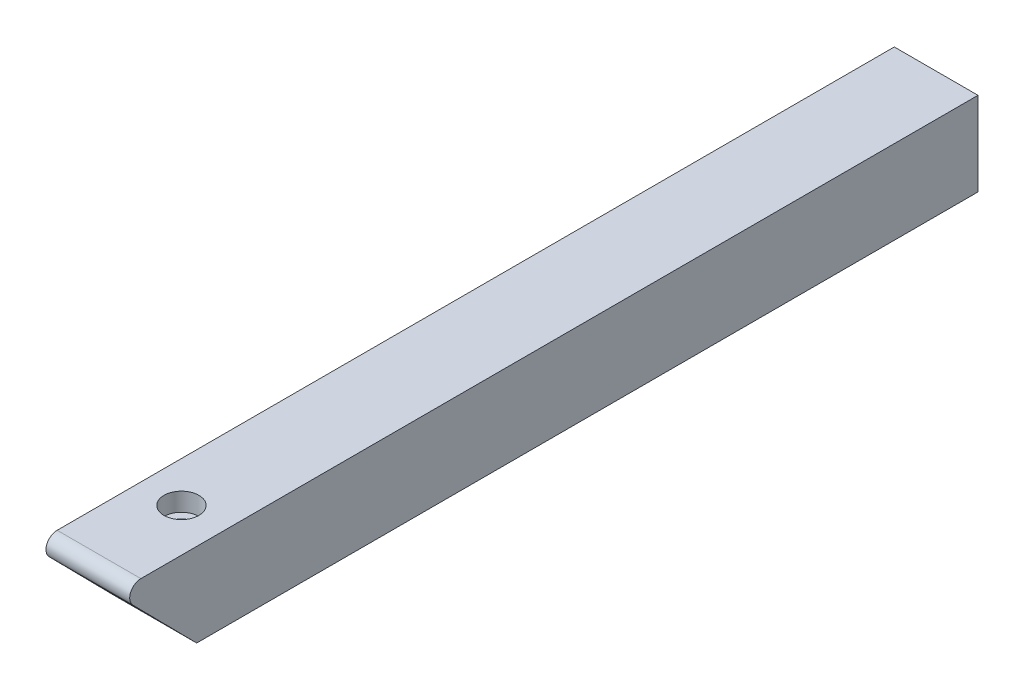
from build123d import *

# Parameters (mm, degrees)
SKETCH1_W                                      = 19.05
SKETCH1_H                                      = 19.05
BOSS_EXTRUDE1_DEPTH                            = 177.8
BOSS_EXTRUDE2_DEPTH                            = 19.05
CBORE_FOR_8_SOCKET_HEAD_CAP_SCREW1_D           = 4.3053
CBORE_FOR_8_SOCKET_HEAD_CAP_SCREW1_DEPTH       = 19.05
CBORE_FOR_8_SOCKET_HEAD_CAP_SCREW1_CBORE_D     = 7.9375
CBORE_FOR_8_SOCKET_HEAD_CAP_SCREW1_CBORE_DEPTH = 4.1656


with BuildPart() as part:
    # Sketch1 → Boss-Extrude1 (new body)
    with BuildSketch(Plane.XY):
        with Locations((9.525, 9.525)):
            Rectangle(SKETCH1_W, SKETCH1_H)
    extrude(amount=BOSS_EXTRUDE1_DEPTH)

    # Sketch2 → Boss-Extrude2 (add)
    with BuildSketch(Plane(origin=(19.05, 0, 0), x_dir=(0, 0, -1), z_dir=(1, 0, 0))):
        with BuildLine():
            Line((-177.8, 19.05), (-190.5, 19.05))
            ThreePointArc((-190.5, 19.05), (-192.843013973, 17.490757626), (-192.309392774, 14.727390174))
            Line((-192.309392774, 14.727390174), (-177.8, 0))
            Line((-177.8, 0), (-177.8, 19.05))
        make_face()
    extrude(amount=-BOSS_EXTRUDE2_DEPTH)

    # CBORE for #8 Socket Head Cap Screw1
    with Locations(Plane(origin=(9.23608704, 19.05, 171.45), x_dir=(0, 0, 1), z_dir=(0, 1, 0))):
        with Locations((0, 0)):
            CounterBoreHole(CBORE_FOR_8_SOCKET_HEAD_CAP_SCREW1_D / 2, CBORE_FOR_8_SOCKET_HEAD_CAP_SCREW1_CBORE_D / 2, CBORE_FOR_8_SOCKET_HEAD_CAP_SCREW1_CBORE_DEPTH, depth=CBORE_FOR_8_SOCKET_HEAD_CAP_SCREW1_DEPTH)


solid = part.part
